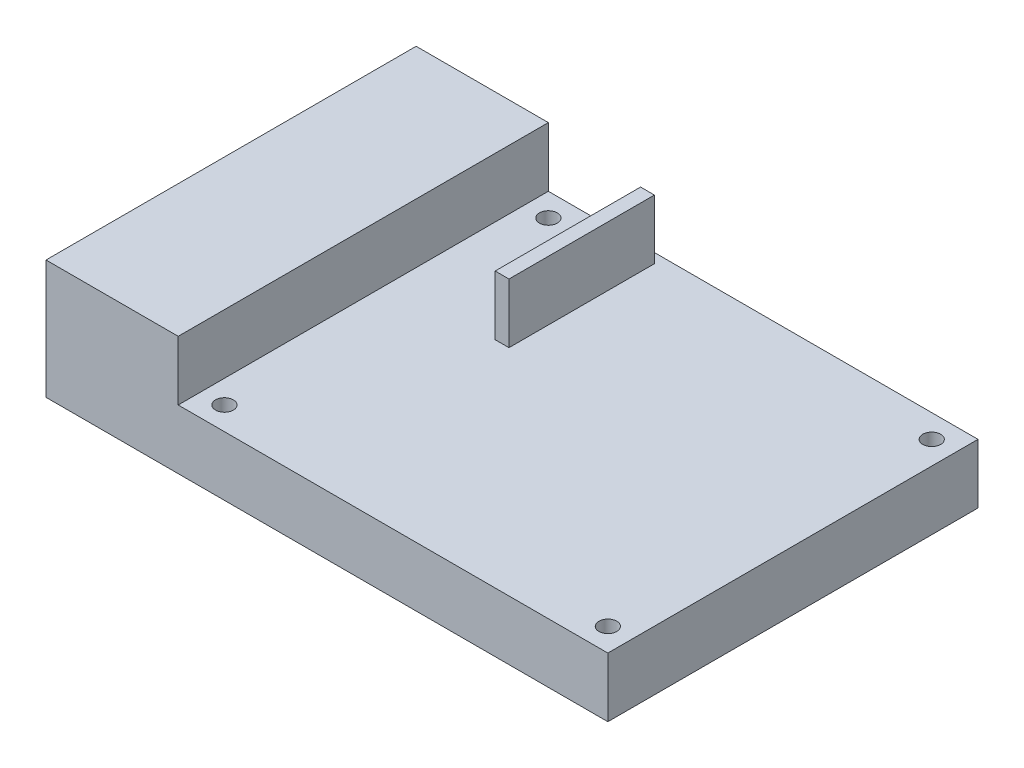
from build123d import *

# Parameters (mm, degrees)
SKETCH1_W             = 20
SKETCH1_H             = 56
BOSS_EXTRUDE1_DEPTH   = 18
SKETCH1_W_2           = 2.09336208
SKETCH1_H_2           = 22
BOSS_EXTRUDE1_2_DEPTH = 18
SKETCH1_3_W           = 65
SKETCH1_3_H           = 56
SKETCH1_3_R           = 1.35
SKETCH1_3_W_2         = 2.09336208
SKETCH1_3_H_2         = 22
BOSS_EXTRUDE2_DEPTH   = 9


with BuildPart() as part:
    # Sketch1 → Boss-Extrude1 (new body)
    with BuildSketch(Plane(origin=(0, 0, 0), x_dir=(1, 0, 0), z_dir=(0, 1, 0))):
        with Locations((10, -28)):
            Rectangle(SKETCH1_W, SKETCH1_H)
    extrude(amount=BOSS_EXTRUDE1_DEPTH)



with BuildPart() as body_2:
    # Sketch1 → Boss-Extrude1 2 (new body)
    with BuildSketch(Plane(origin=(0, 0, 0), x_dir=(1, 0, 0), z_dir=(0, 1, 0))):
        with Locations((36.46668104, -12.469488465)):
            Rectangle(SKETCH1_W_2, SKETCH1_H_2)
    extrude(amount=BOSS_EXTRUDE1_2_DEPTH)


with BuildPart() as part_1:
    add(part.part)

    add(body_2.part)  # Boss-Extrude2 merges body 2
    # Sketch1_3 → Boss-Extrude2 (add)
    with BuildSketch(Plane(origin=(0, 0, 0), x_dir=(1, 0, 0), z_dir=(0, 1, 0))):
        with Locations((52.5, -28)):
            Rectangle(SKETCH1_3_W, SKETCH1_3_H)
        with Locations((23.5, -52.5)):
            Circle(SKETCH1_3_R, mode=Mode.SUBTRACT)
        with Locations((81.5, -52.5)):
            Circle(SKETCH1_3_R, mode=Mode.SUBTRACT)
        with Locations((36.46668104, -12.469488465)):
            Rectangle(SKETCH1_3_W_2, SKETCH1_3_H_2, mode=Mode.SUBTRACT)
        with Locations((23.5, -3.5)):
            Circle(SKETCH1_3_R, mode=Mode.SUBTRACT)
        with Locations((81.5, -3.5)):
            Circle(SKETCH1_3_R, mode=Mode.SUBTRACT)
    extrude(amount=BOSS_EXTRUDE2_DEPTH)


solid = part_1.part
